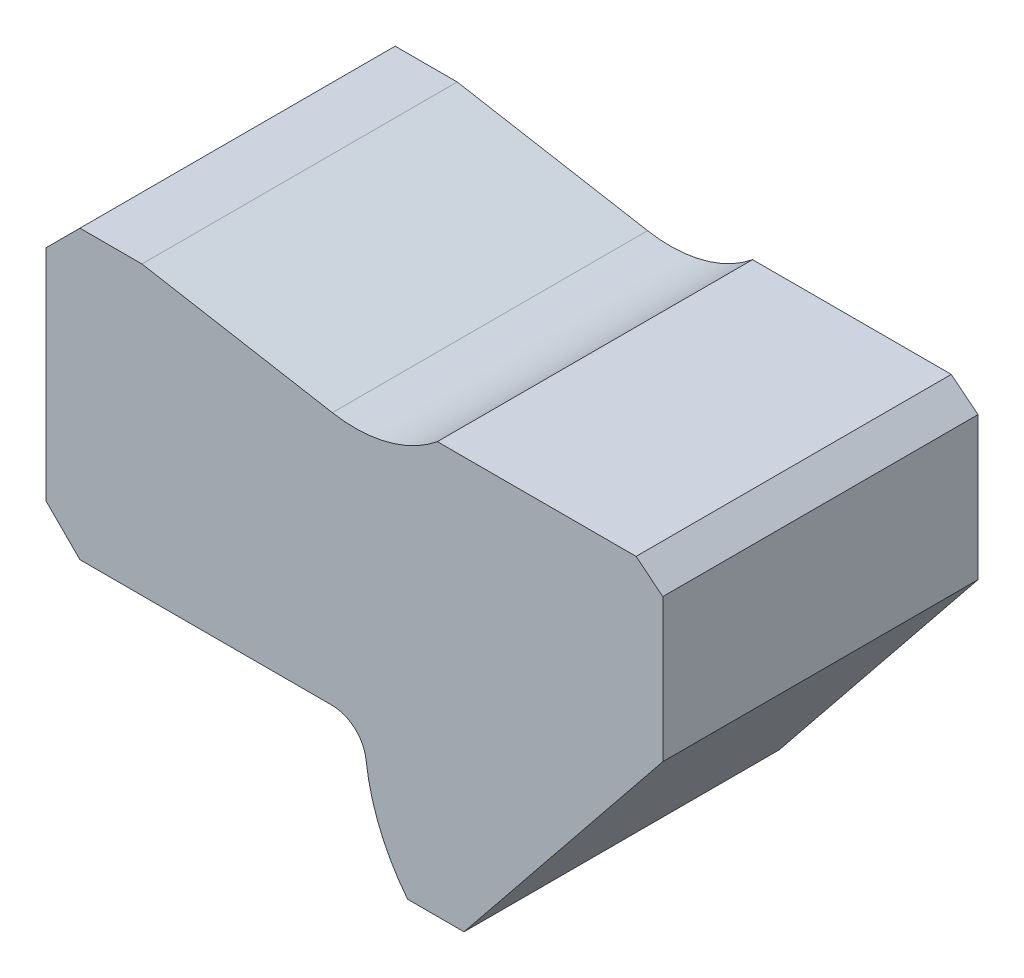
from build123d import *

# Parameters (mm, degrees)
DODANIE_WYCI_GNI_CIE1_DEPTH = 46


with BuildPart() as part:
    # Szkic1 → Dodanie-wyciągnięcie1 (new body)
    with BuildSketch(Plane.XY):
        with BuildLine():
            Line((0, 0), (8.237634002, 0))
            Line((8.237634002, 0), (37.237634002, 36))
            Line((37.237634002, 36), (37.237634002, 56.863352311))
            Line((37.237634002, 56.863352311), (33.343864456, 60))
            Line((33.343864456, 60), (4.343864456, 60))
            ThreePointArc((4.343864456, 60), (-2.880934736, 56.327791154), (-10.978818754, 56.000505938))
            Line((-10.978818754, 56.000505938), (-38.762365998, 60.899494937))
            Line((-38.762365998, 60.899494937), (-47.81261853, 60.899494937))
            Line((-47.81261853, 60.899494937), (-52.762365998, 55.949747468))
            Line((-52.762365998, 55.949747468), (-52.762365998, 23.949747468))
            Line((-52.762365998, 23.949747468), (-47.81261853, 19))
            Line((-47.81261853, 19), (-11.02625203, 19))
            ThreePointArc((-11.02625203, 19), (-7.70519621, 17.737725008), (-6.060974673, 14.588235294))
            ThreePointArc((-6.060974673, 14.588235294), (-4.04296027, 6.873465479), (0, 0))
        make_face()
    extrude(amount=DODANIE_WYCI_GNI_CIE1_DEPTH)


solid = part.part
